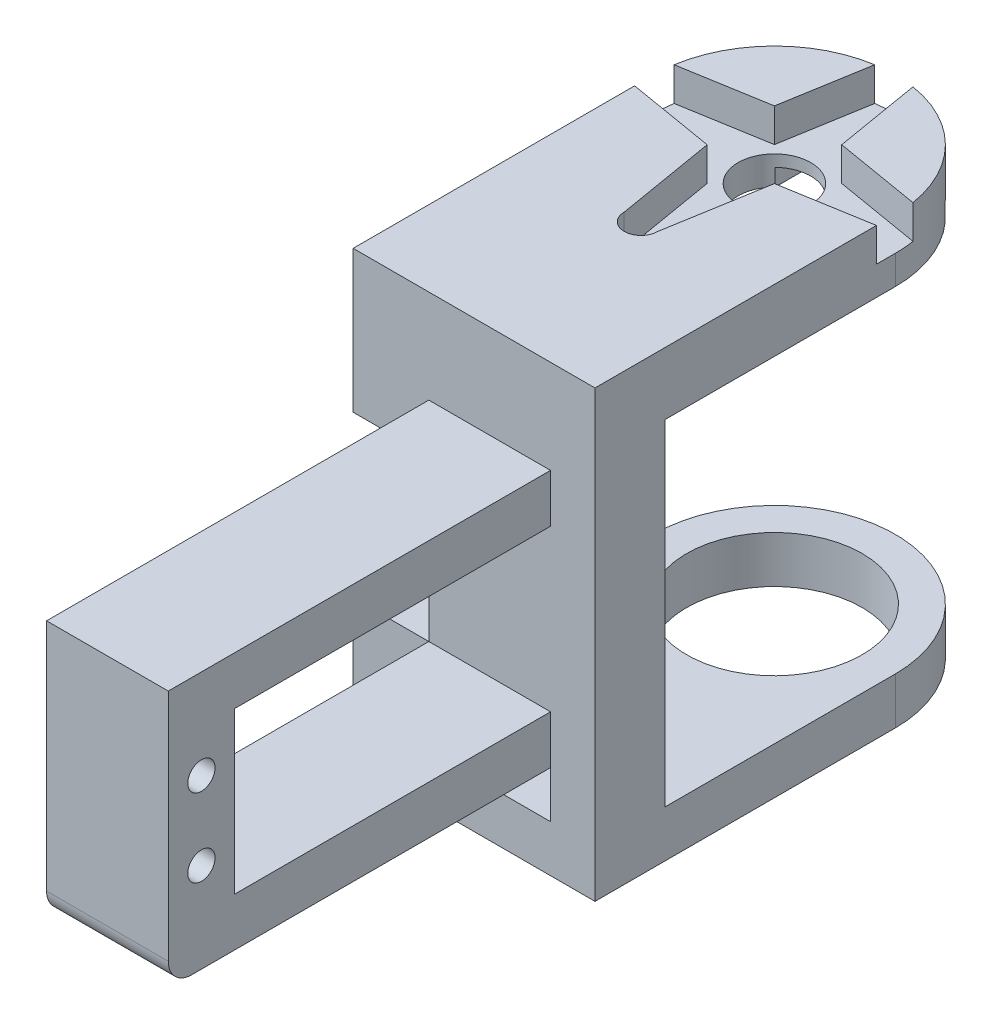
from build123d import *

# Parameters (mm, degrees)
SKETCH1_W           = 18.3
SKETCH1_H           = 6
BOSS_EXTRUDE1_DEPTH = 9
SKETCH2_W           = 15.6
SKETCH2_H           = 6.2
BOSS_EXTRUDE2_DEPTH = 49
SKETCH3_W           = 15.6
SKETCH3_H           = 8.5
BOSS_EXTRUDE3_DEPTH = 20.7
FILLET3_R           = 3
SKETCH4_W           = 31
SKETCH4_H           = 8
SKETCH4_H_2         = 6
BOSS_EXTRUDE4_DEPTH = 45
CUT_EXTRUDE1_DEPTH  = 58
SKETCH6_3_R         = 11.25
CUT_EXTRUDE2_DEPTH  = 6
CUT_EXTRUDE3_DEPTH  = 4.3
CUT_EXTRUDE4_DEPTH  = 2.2
SKETCH9_3_R         = 4.65
CUT_EXTRUDE5_DEPTH  = 8
SKETCH10_R          = 1.75
CUT_EXTRUDE6_DEPTH  = 18


with BuildPart() as part:
    # Sketch1 → Boss-Extrude1 (new body)
    with BuildSketch(Plane.XY):
        Polygon((15.5, -28.5), (-15.5, -28.5), (-15.5, -10.3), (-5.8, -10.3), (-5.8, 10.3), (-15.5, 10.3), (-15.5, 28.5), (15.5, 28.5), align=None)
        with Locations((0.65, -19.5)):
            Rectangle(SKETCH1_W, SKETCH1_H, mode=Mode.SUBTRACT)
    extrude(amount=BOSS_EXTRUDE1_DEPTH)

    # Sketch2 → Boss-Extrude2 (add)
    with BuildSketch(Plane.XY.offset(9)):
        with Locations((2, -13.4)):
            Rectangle(SKETCH2_W, SKETCH2_H)
        with Locations((2, 13.4)):
            Rectangle(SKETCH2_W, SKETCH2_H)
    extrude(amount=BOSS_EXTRUDE2_DEPTH)

    # Sketch3 → Boss-Extrude3 (add)
    with BuildSketch(Plane.XZ.offset(-10.3)):
        with Locations((2, 53.75)):
            Rectangle(SKETCH3_W, SKETCH3_H)
    extrude(amount=BOSS_EXTRUDE3_DEPTH)

    # Fillet3
    fillet3_edges = [part.edges().sort_by_distance(p)[0] for p in [
        (2, -16.5, 58),
    ]]
    fillet(fillet3_edges, radius=FILLET3_R)

    # Sketch4 → Boss-Extrude4 (add)
    with BuildSketch(Plane(origin=(0, 0, 0), x_dir=(-1, 0, 0), z_dir=(0, 0, -1))):
        with Locations((0, 24.5)):
            Rectangle(SKETCH4_W, SKETCH4_H)
        with Locations((0, -25.5)):
            Rectangle(SKETCH4_W, SKETCH4_H_2)
    extrude(amount=BOSS_EXTRUDE4_DEPTH)

    # Sketch6 → Cut-Extrude1 (cut, through all)
    with BuildSketch(Plane.XZ.offset(28.5)):
        with BuildLine():
            ThreePointArc((15.5, -29.5), (10.960155101, -40.460155116), (-2.1e-08, -45))
            Line((-2.1e-08, -45), (15.5, -45))
            Line((15.5, -45), (15.5, -29.5))
        make_face()
        with BuildLine():
            ThreePointArc((-2.1e-08, -45), (-10.960155116, -40.460155101), (-15.5, -29.5))
            Line((-15.5, -29.5), (-15.5, -45))
            Line((-15.5, -45), (-2.1e-08, -45))
        make_face()
    extrude(amount=-CUT_EXTRUDE1_DEPTH, mode=Mode.SUBTRACT)

    # Sketch6_3 → Cut-Extrude2 (cut)
    with BuildSketch(Plane.XZ.offset(28.5)):
        with Locations((0, -29.5)):
            Circle(SKETCH6_3_R)
    extrude(amount=-CUT_EXTRUDE2_DEPTH, mode=Mode.SUBTRACT)

    # Sketch7 → Cut-Extrude3 (cut)
    with BuildSketch(Plane(origin=(0, 28.5, 0), x_dir=(1, 0, 0), z_dir=(0, 1, 0))):
        with BuildLine():
            Line((-17.1, 31.65), (-4.313351365, 33.813351365))
            Line((-4.313351365, 33.813351365), (-2.15, 46.6))
            ThreePointArc((-2.15, 46.6), (0, 48.75), (2.15, 46.6))
            Line((2.15, 46.6), (4.313351365, 33.813351365))
            Line((4.313351365, 33.813351365), (17.1, 31.65))
            ThreePointArc((17.1, 31.65), (19.25, 29.5), (17.1, 27.35))
            Line((17.1, 27.35), (4.313351365, 25.186648635))
            Line((4.313351365, 25.186648635), (2.15, 12.4))
            ThreePointArc((2.15, 12.4), (0, 10.25), (-2.15, 12.4))
            Line((-2.15, 12.4), (-4.313351365, 25.186648635))
            Line((-4.313351365, 25.186648635), (-17.1, 27.35))
            ThreePointArc((-17.1, 27.35), (-19.25, 29.5), (-17.1, 31.65))
        make_face()
    extrude(amount=-CUT_EXTRUDE3_DEPTH, mode=Mode.SUBTRACT)

    # Sketch9 → Cut-Extrude4 (cut)
    with BuildSketch(Plane.XZ.offset(-20.5)):
        with BuildLine():
            ThreePointArc((3.25, -32.82565783), (0, -34.15), (-3.25, -32.82565783))
            Line((-3.25, -32.82565783), (-3.25, -44.655444566))
            ThreePointArc((-3.25, -44.655444566), (0, -45), (3.25, -44.655444566))
            Line((3.25, -44.655444566), (3.25, -32.82565783))
        make_face()
    extrude(amount=-CUT_EXTRUDE4_DEPTH, mode=Mode.SUBTRACT)

    # Sketch9_3 → Cut-Extrude5 (cut)
    with BuildSketch(Plane.XZ.offset(-20.5)):
        with Locations((0, -29.5)):
            Circle(SKETCH9_3_R)
    extrude(amount=-CUT_EXTRUDE5_DEPTH, mode=Mode.SUBTRACT)

    # Sketch10 → Cut-Extrude6 (cut)
    with BuildSketch(Plane.ZY.offset(5.8)):
        with Locations((4.5, 5)):
            Circle(SKETCH10_R)
        with Locations((4.5, -5)):
            Circle(SKETCH10_R)
        with Locations((53.75, 5)):
            Circle(SKETCH10_R)
        with Locations((53.75, -5)):
            Circle(SKETCH10_R)
    extrude(amount=-CUT_EXTRUDE6_DEPTH, mode=Mode.SUBTRACT)


solid = part.part
